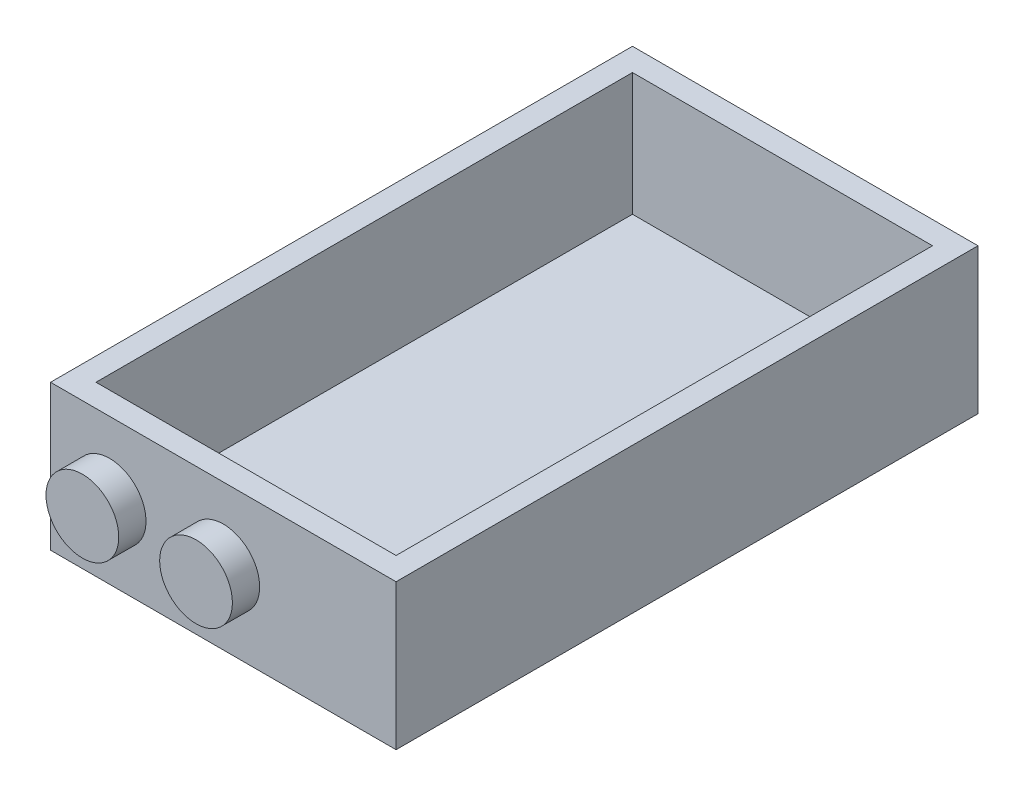
from build123d import *

# Parameters (mm, degrees)
SKETCH1_W           = 38
SKETCH1_H           = 64
BOSS_EXTRUDE1_DEPTH = 16
SKETCH2_R           = 4
BOSS_EXTRUDE2_DEPTH = 3
SHELL1_T            = -2.5


with BuildPart() as part:
    # Sketch1 → Boss-Extrude1 (new body)
    with BuildSketch(Plane(origin=(0, 0, 0), x_dir=(1, 0, 0), z_dir=(0, 1, 0))):
        with Locations((19, -32)):
            Rectangle(SKETCH1_W, SKETCH1_H)
    extrude(amount=BOSS_EXTRUDE1_DEPTH)

    # Sketch2 → Boss-Extrude2 (add)
    with BuildSketch(Plane.XY.offset(64)):
        with Locations((19, 8)):
            Circle(SKETCH2_R)
        with Locations((6.5, 8)):
            Circle(SKETCH2_R)
    extrude(amount=BOSS_EXTRUDE2_DEPTH)

    # Shell1
    shell1_openings = [part.faces().sort_by_distance(p)[0] for p in [
        (19, 16, 32),
    ]]
    offset(amount=SHELL1_T, openings=shell1_openings, kind=Kind.INTERSECTION)


solid = part.part
